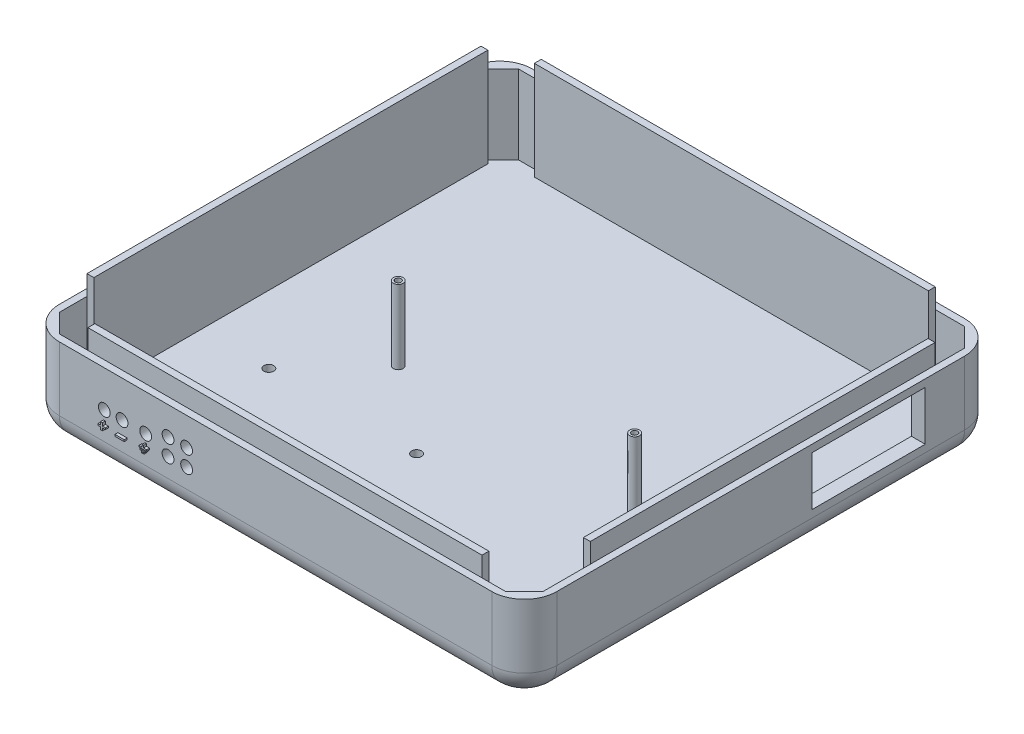
from build123d import *

# Parameters (mm, degrees)
SKETCH1_W            = 107.95
SKETCH1_H            = 101.6
BOSS_EXTRUDE1_DEPTH  = 2.54
SKETCH17_W           = 107.95
SKETCH17_H           = 2.54
BOSS_EXTRUDE11_DEPTH = 10.16
SKETCH20_W           = 111.76
SKETCH20_H           = 2.54
BOSS_EXTRUDE12_DEPTH = 10.16
SKETCH21_W           = 118.11
SKETCH21_H           = 2.54
BOSS_EXTRUDE13_DEPTH = 10.16
SKETCH22_W           = 121.92
SKETCH22_H           = 2.54
BOSS_EXTRUDE14_DEPTH = 10.16
SKETCH26_W           = 128.27
SKETCH26_H           = 121.92
BOSS_EXTRUDE18_DEPTH = 20.32
FILLET9_R            = 8.382
FILLET10_R           = 8.382
FILLET11_R           = 8.382
SKETCH28_W           = 101.6
SKETCH28_H           = 1.778
BOSS_EXTRUDE21_DEPTH = 25.4
SKETCH29_W           = 1.778
SKETCH29_H           = 88.9
BOSS_EXTRUDE22_DEPTH = 25.4
FILLET21_R           = 8.382
SKETCH30_W           = 101.6
SKETCH30_H           = 1.778
BOSS_EXTRUDE23_DEPTH = 25.4
SKETCH31_W           = 1.778
SKETCH31_H           = 101.6
BOSS_EXTRUDE24_DEPTH = 25.4
SKETCH32_R           = 1.524
CUT_EXTRUDE1_DEPTH   = 3.556
FILLET22_R           = 6.35
SKETCH34_W           = 2.376451265
SKETCH34_H           = 0.450830227
BOSS_EXTRUDE26_DEPTH = 0.762
BOSS_EXTRUDE27_DEPTH = 0.762
BOSS_EXTRUDE28_DEPTH = 0.762
SKETCH37_W           = 1.40164535
SKETCH37_H           = 0.295981153
BOSS_EXTRUDE29_DEPTH = 0.762
SKETCH38_W           = 0.721341472
SKETCH38_H           = 0.249868222
BOSS_EXTRUDE30_DEPTH = 0.762
SKETCH4_R            = 1.27
SKETCH4_R_2          = 0.762
BOSS_EXTRUDE31_DEPTH = 19.05
SKETCH40_R           = 1.524
CUT_EXTRUDE2_DEPTH   = 3.556
SKETCH42_W           = 29.21
SKETCH42_H           = 12.7
CUT_EXTRUDE3_DEPTH   = 3.556
SKETCH43_R           = 1.27
CUT_EXTRUDE4_DEPTH   = 2.54


with BuildPart() as part:
    # Sketch1 → Boss-Extrude1 (new body)
    with BuildSketch(Plane(origin=(0, 0, 0), x_dir=(1, 0, 0), z_dir=(0, 1, 0))):
        with Locations((-9.276565374, 13.725713086)):
            Rectangle(SKETCH1_W, SKETCH1_H)
    extrude(amount=BOSS_EXTRUDE1_DEPTH)

    # Sketch17 → Boss-Extrude11 (add)
    with BuildSketch(Plane(origin=(0, 0, -64.525713086), x_dir=(-1, 0, 0), z_dir=(0, 0, -1))):
        with Locations((9.276565374, 1.27)):
            Rectangle(SKETCH17_W, SKETCH17_H)
    extrude(amount=BOSS_EXTRUDE11_DEPTH)

    # Sketch20 → Boss-Extrude12 (add)
    with BuildSketch(Plane(origin=(44.698434626, 0, 0), x_dir=(0, 0, -1), z_dir=(1, 0, 0))):
        with Locations((18.805713086, 1.27)):
            Rectangle(SKETCH20_W, SKETCH20_H)
    extrude(amount=BOSS_EXTRUDE12_DEPTH)

    # Sketch21 → Boss-Extrude13 (add)
    with BuildSketch(Plane.XY.offset(37.074286914)):
        with Locations((-4.196565374, 1.27)):
            Rectangle(SKETCH21_W, SKETCH21_H)
    extrude(amount=BOSS_EXTRUDE13_DEPTH)

    # Sketch22 → Boss-Extrude14 (add)
    with BuildSketch(Plane.ZY.offset(63.251565374)):
        with Locations((-13.725713086, 1.27)):
            Rectangle(SKETCH22_W, SKETCH22_H)
    extrude(amount=BOSS_EXTRUDE14_DEPTH)

    # Sketch26 → Boss-Extrude18 (add)
    with BuildSketch(Plane(origin=(0, 2.54, 0), x_dir=(1, 0, 0), z_dir=(0, 1, 0))):
        with Locations((-9.276565374, 13.725713086)):
            Rectangle(SKETCH26_W, SKETCH26_H)
        Polygon((42.711561077, -45.456286914), (-66.807565374, -45.456286914), (-71.633565374, -40.630286914), (-71.633565374, -37.536996118), (-71.633565374, 66.303713086), (-71.633565374, 68.081713086), (-66.807565374, 72.907713086), (-62.278091081, 72.907713086), (48.254434626, 72.907713086), (53.080434626, 68.081713086), (53.080434626, -38.852286914), (53.080434626, -40.630286914), (48.254434626, -45.456286914), align=None, mode=Mode.SUBTRACT)
    extrude(amount=BOSS_EXTRUDE18_DEPTH)

    # Fillet9
    fillet9_edges = [part.edges().sort_by_distance(p)[0] for p in [
        (-73.411565374, 11.43, 47.234286914),
    ]]
    fillet(fillet9_edges, radius=FILLET9_R)

    # Fillet10
    fillet10_edges = [part.edges().sort_by_distance(p)[0] for p in [
        (54.858434626, 11.43, 47.234286914),
    ]]
    fillet(fillet10_edges, radius=FILLET10_R)

    # Fillet11
    fillet11_edges = [part.edges().sort_by_distance(p)[0] for p in [
        (-73.411565374, 11.43, -74.685713086),
    ]]
    fillet(fillet11_edges, radius=FILLET11_R)

    # Sketch28 → Boss-Extrude21 (add)
    with BuildSketch(Plane(origin=(0, 2.54, 0), x_dir=(1, 0, 0), z_dir=(0, 1, 0))):
        with Locations((-8.643546278, -44.567286914)):
            Rectangle(SKETCH28_W, SKETCH28_H)
    extrude(amount=BOSS_EXTRUDE21_DEPTH)

    # Sketch29 → Boss-Extrude22 (add)
    with BuildSketch(Plane(origin=(0, 2.54, 0), x_dir=(1, 0, 0), z_dir=(0, 1, 0))):
        with Locations((52.191434626, 16.003984914)):
            Rectangle(SKETCH29_W, SKETCH29_H)
    extrude(amount=BOSS_EXTRUDE22_DEPTH)

    # Fillet21
    fillet21_edges = [part.edges().sort_by_distance(p)[0] for p in [
        (54.858434626, 11.43, -74.685713086),
    ]]
    fillet(fillet21_edges, radius=FILLET21_R)

    # Sketch30 → Boss-Extrude23 (add)
    with BuildSketch(Plane(origin=(0, 2.54, 0), x_dir=(1, 0, 0), z_dir=(0, 1, 0))):
        with Locations((-10.117650569, 72.018713086)):
            Rectangle(SKETCH30_W, SKETCH30_H)
    extrude(amount=BOSS_EXTRUDE23_DEPTH)

    # Sketch31 → Boss-Extrude24 (add)
    with BuildSketch(Plane(origin=(0, 2.54, 0), x_dir=(1, 0, 0), z_dir=(0, 1, 0))):
        with Locations((-70.744565374, 17.281544489)):
            Rectangle(SKETCH31_W, SKETCH31_H)
    extrude(amount=BOSS_EXTRUDE24_DEPTH)

    # Sketch32 → Cut-Extrude1 (cut)
    with BuildSketch(Plane.XY.offset(47.234286914)):
        with Locations((-53.446124862, 13.468430173)):
            Circle(SKETCH32_R)
        with Locations((-48.874124862, 13.468430173)):
            Circle(SKETCH32_R)
        with Locations((-42.778124862, 13.468430173)):
            Circle(SKETCH32_R)
    extrude(amount=-CUT_EXTRUDE1_DEPTH, mode=Mode.SUBTRACT)

    # Fillet22
    fillet22_edges = [part.edges().sort_by_distance(p)[0] for p in [
        (-9.276565374, 0, 47.234286914),
        (-70.956534413, 0, 44.779255954),
        (54.858434626, 0, -13.725713086),
        (52.403403666, 0, 44.779255954),
        (-73.411565374, 0, -13.725713086),
        (-70.956534413, 0, -72.230682126),
        (-9.276565374, 0, -74.685713086),
        (52.403403666, 0, -72.230682126),
    ]]
    fillet(fillet22_edges, radius=FILLET22_R)

    # Sketch34 → Boss-Extrude26 (add)
    with BuildSketch(Plane.XY.offset(47.234286914)):
        with Locations((-48.746578478, 9.905961703)):
            Rectangle(SKETCH34_W, SKETCH34_H)
    extrude(amount=BOSS_EXTRUDE26_DEPTH)

    # Sketch35 → Boss-Extrude27 (add)
    with BuildSketch(Plane.XY.offset(47.234286914)):
        Polygon((-53.675043022, 11.10789921), (-53.182867877, 11.10789921), (-53.182867877, 10.345394629), (-52.415207401, 10.345394629), (-52.415207401, 9.941250014), (-53.182867877, 9.941250014), (-53.182867877, 9.28546766), (-53.675043022, 9.28546766), (-53.675043022, 9.941250014), (-54.332901543, 9.941250014), (-54.332901543, 10.345394629), (-53.675043022, 10.345394629), align=None)
    extrude(amount=BOSS_EXTRUDE27_DEPTH)

    # Sketch36 → Boss-Extrude28 (add)
    with BuildSketch(Plane.XY.offset(47.234286914)):
        Polygon((-42.938376237, 10.774794696), (-42.938376237, 11.391124792), (-42.570939626, 11.391124792), (-42.570939626, 10.774794696), (-41.773582858, 10.774794696), (-41.773582858, 10.421472403), (-43.74903155, 10.421472403), (-43.74903155, 10.774794696), align=None)
    extrude(amount=BOSS_EXTRUDE28_DEPTH)

    # Sketch37 → Boss-Extrude29 (add)
    with BuildSketch(Plane.XY.offset(47.234286914)):
        with Locations((-42.779535982, 10.098380285)):
            Rectangle(SKETCH37_W, SKETCH37_H)
    extrude(amount=BOSS_EXTRUDE29_DEPTH)

    # Sketch38 → Boss-Extrude30 (add)
    with BuildSketch(Plane.XY.offset(47.234286914)):
        with Locations((-42.785601146, 9.583230105)):
            Rectangle(SKETCH38_W, SKETCH38_H)
    extrude(amount=BOSS_EXTRUDE30_DEPTH)

    # Sketch4 → Boss-Extrude31 (add)
    with BuildSketch(Plane(origin=(0, 2.54, 0), x_dir=(1, 0, 0), z_dir=(0, 1, 0))):
        with Locations((-36.327565374, 11.439713086)):
            Circle(SKETCH4_R)
        with Locations((-36.327565374, 11.439713086)):
            Circle(SKETCH4_R_2, mode=Mode.SUBTRACT)
        with Locations((28.188434626, 7.883713086)):
            Circle(SKETCH4_R)
        with Locations((28.188434626, 7.883713086)):
            Circle(SKETCH4_R_2, mode=Mode.SUBTRACT)
    extrude(amount=BOSS_EXTRUDE31_DEPTH)

    # Sketch40 → Cut-Extrude2 (cut)
    with BuildSketch(Plane.XY.offset(47.234286914)):
        with Locations((-37.012349316, 15.614831818)):
            Circle(SKETCH40_R)
        with Locations((-32.223462278, 15.614831818)):
            Circle(SKETCH40_R)
        with Locations((-37.012349316, 11.291329779)):
            Circle(SKETCH40_R)
        with Locations((-32.223462278, 11.291329779)):
            Circle(SKETCH40_R)
    extrude(amount=-CUT_EXTRUDE2_DEPTH, mode=Mode.SUBTRACT)

    # Sketch42 → Cut-Extrude3 (cut)
    with BuildSketch(Plane(origin=(54.858434626, 0, 0), x_dir=(0, 0, -1), z_dir=(1, 0, 0))):
        with Locations((41.538713086, 14.605)):
            Rectangle(SKETCH42_W, SKETCH42_H)
    extrude(amount=-CUT_EXTRUDE3_DEPTH, mode=Mode.SUBTRACT)

    # Sketch43 → Cut-Extrude4 (cut)
    with BuildSketch(Plane(origin=(0, 2.54, 0), x_dir=(1, 0, 0), z_dir=(0, 1, 0))):
        with Locations((-14.323930267, -5.830780993)):
            Circle(SKETCH43_R)
        with Locations((-52.423930267, -5.830780993)):
            Circle(SKETCH43_R)
        with Locations((-52.423930267, -38.850780993)):
            Circle(SKETCH43_R)
        with Locations((-14.323930267, -38.850780993)):
            Circle(SKETCH43_R)
    extrude(amount=-CUT_EXTRUDE4_DEPTH, mode=Mode.SUBTRACT)


solid = part.part
